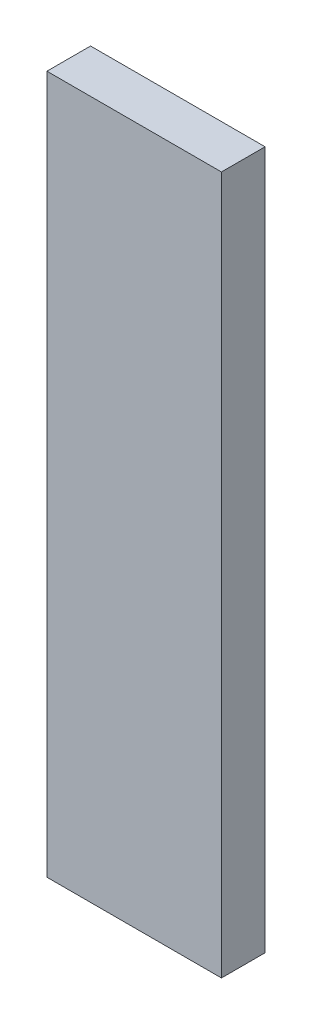
from build123d import *

# Parameters (mm, degrees)
SKETCH1_W           = 25.4
SKETCH1_H           = 6.35
BOSS_EXTRUDE1_DEPTH = 101.6


with BuildPart() as part:
    # Sketch1 → Boss-Extrude1 (new body)
    with BuildSketch(Plane(origin=(0, 0, 0), x_dir=(1, 0, 0), z_dir=(0, 1, 0))):
        with Locations((12.7, 3.175)):
            Rectangle(SKETCH1_W, SKETCH1_H)
    extrude(amount=BOSS_EXTRUDE1_DEPTH)


solid = part.part
